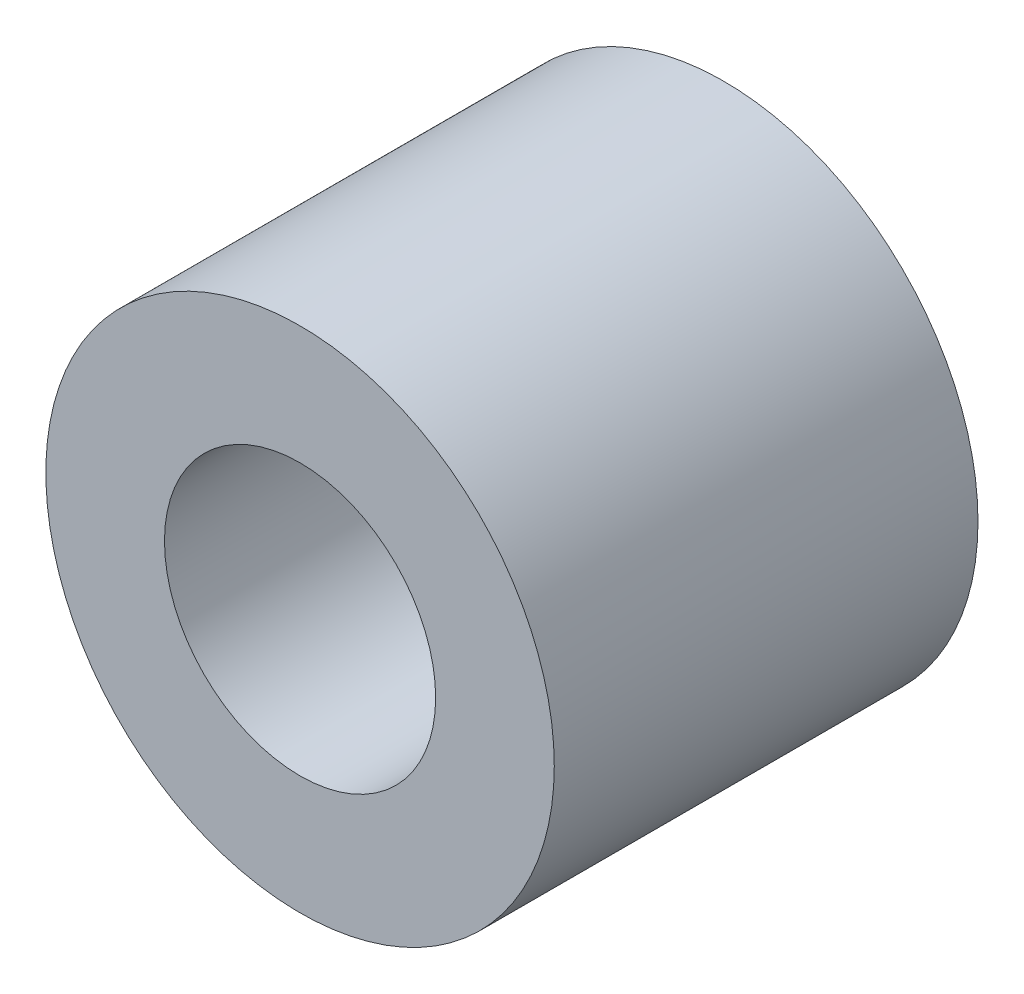
from build123d import *

# Parameters (mm, degrees)
SKETCH1_R           = 3
SKETCH1_R_2         = 1.6
BOSS_EXTRUDE1_DEPTH = 5


with BuildPart() as part:
    # Sketch1 → Boss-Extrude1 (new body)
    with BuildSketch(Plane.XY):
        Circle(SKETCH1_R)
        Circle(SKETCH1_R_2, mode=Mode.SUBTRACT)
    extrude(amount=BOSS_EXTRUDE1_DEPTH)


solid = part.part
